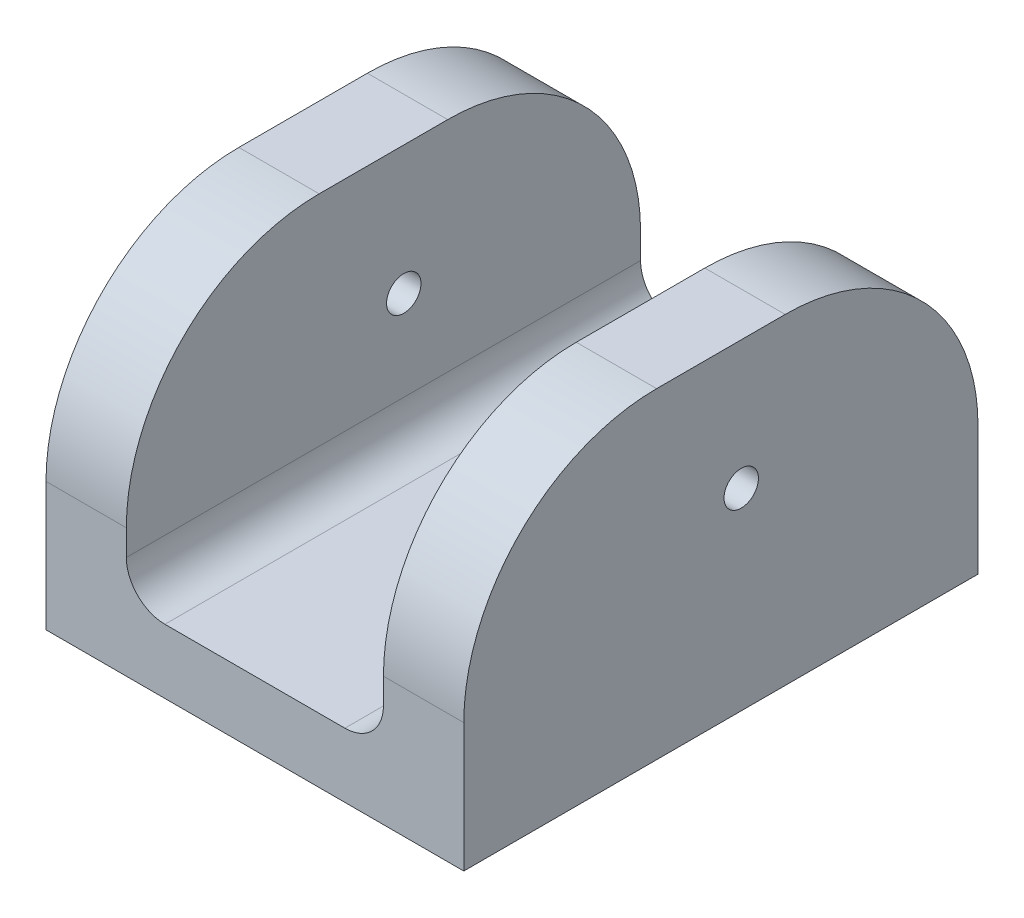
from build123d import *

# Parameters (mm, degrees)
BOSS_EXTRUDE1_DEPTH         = 50.8
FILLET1_R                   = 19.05
FILLET3_R                   = 3.81
F_1_4_20_TAPPED_HOLE1_D     = 5.1054
F_1_4_20_TAPPED_HOLE1_DEPTH = 19.05
F_1_4_20_TAPPED_HOLE1_TIP   = 1.533816902
M3_CLEARANCE_HOLE2_D        = 3.4


with BuildPart() as part:
    # Sketch1 → Boss-Extrude1 (new body)
    with BuildSketch(Plane.XY):
        Polygon((-20.6375, 0), (20.6375, 0), (20.6375, 6.35), (20.6375, 31.75), (12.7, 31.75), (12.7, 6.35), (-12.7, 6.35), (-12.7, 31.75), (-20.6375, 31.75), (-20.6375, 6.35), align=None)
    extrude(amount=BOSS_EXTRUDE1_DEPTH)

    # Fillet1
    fillet1_edges = [part.edges().sort_by_distance(p)[0] for p in [
        (-16.66875, 31.75, 0),
        (16.66875, 31.75, 50.8),
        (16.66875, 31.75, 0),
        (-16.66875, 31.75, 50.8),
    ]]
    fillet(fillet1_edges, radius=FILLET1_R)

    # Fillet3
    fillet3_edges = [part.edges().sort_by_distance(p)[0] for p in [
        (-12.7, 6.35, 25.4),
        (12.7, 6.35, 25.4),
    ]]
    fillet(fillet3_edges, radius=FILLET3_R)

    # 1/4-20 Tapped Hole1
    with Locations(Plane(origin=(0, 0, 0), x_dir=(-1, 0, 0), z_dir=(0, -1, 0))):
        with Locations((-16.66875, -3.96875), (16.66875, -3.96875), (16.66875, -46.83125), (-16.66875, -46.83125)):
            Hole(F_1_4_20_TAPPED_HOLE1_D / 2, depth=F_1_4_20_TAPPED_HOLE1_DEPTH)
            with Locations((0, 0, -(F_1_4_20_TAPPED_HOLE1_DEPTH + F_1_4_20_TAPPED_HOLE1_TIP / 2))):  # 118° drill point
                Cone(0, F_1_4_20_TAPPED_HOLE1_D / 2, F_1_4_20_TAPPED_HOLE1_TIP, mode=Mode.SUBTRACT)

    # M3 Clearance Hole2 (through all)
    with Locations(Plane(origin=(20.6375, 0, 0), x_dir=(0, 0, -1), z_dir=(1, 0, 0))):
        with Locations((-23.391086867, 19.05)):
            Hole(M3_CLEARANCE_HOLE2_D / 2)


solid = part.part
